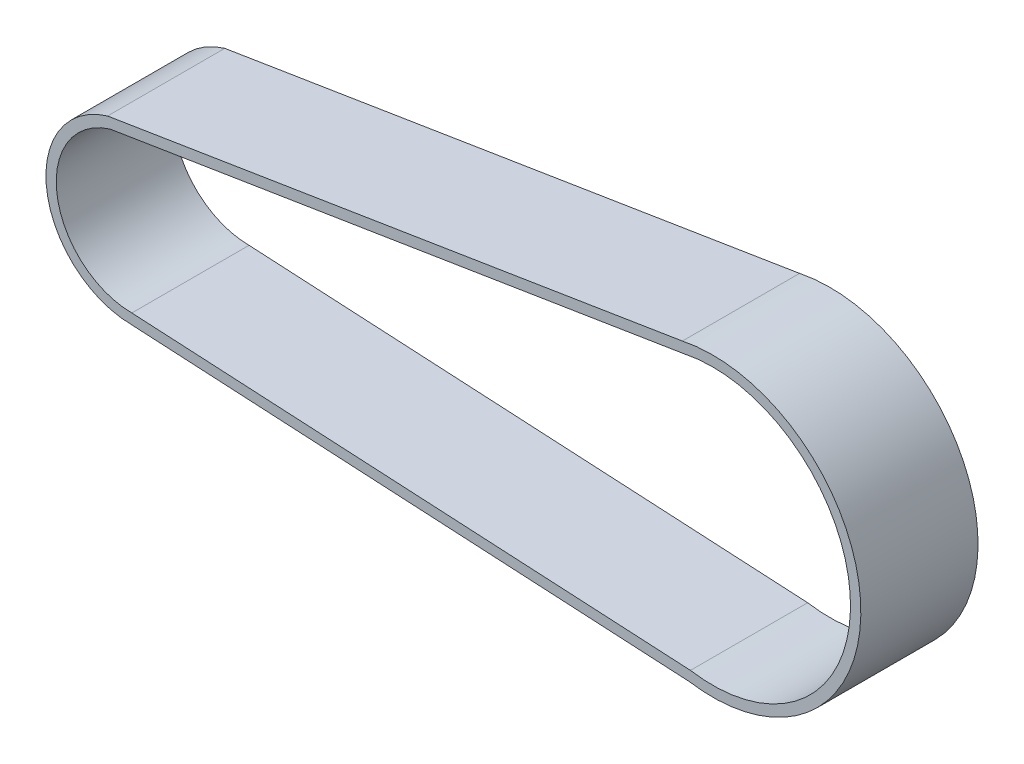
from build123d import *

# Parameters (mm, degrees)
BOSS_EXTRUDE1_DEPTH = 17


with BuildPart() as part:
    # Sketch1 → Boss-Extrude1 (new body)
    with BuildSketch(Plane.XY):
        with BuildLine():
            Line((-3.552757832, 11.984486296), (79.821801563, 25.401697222))
            ThreePointArc((79.821801563, 25.401697222), (105.705914613, 4.870060066), (80.835524125, -16.878482636))
            Line((80.835524125, -16.878482636), (-0.077282043, -12.499761097))
            ThreePointArc((-0.077282043, -12.499761097), (-12.375939964, -1.756732768), (-3.552757832, 11.984486296))
        make_face()
        with BuildLine():
            Line((-3.215991075, 10.519382178), (80.094875313, 23.926343184))
            ThreePointArc((80.094875313, 23.926343184), (104.206843058, 4.812887116), (80.995673674, -15.384954532))
            Line((80.995673674, -15.384954532), (-0.033237623, -10.999949784))
            ThreePointArc((-0.033237623, -10.999949784), (-10.881625973, -1.60941486), (-3.215991075, 10.519382178))
        make_face(mode=Mode.SUBTRACT)
    extrude(amount=BOSS_EXTRUDE1_DEPTH)


solid = part.part
